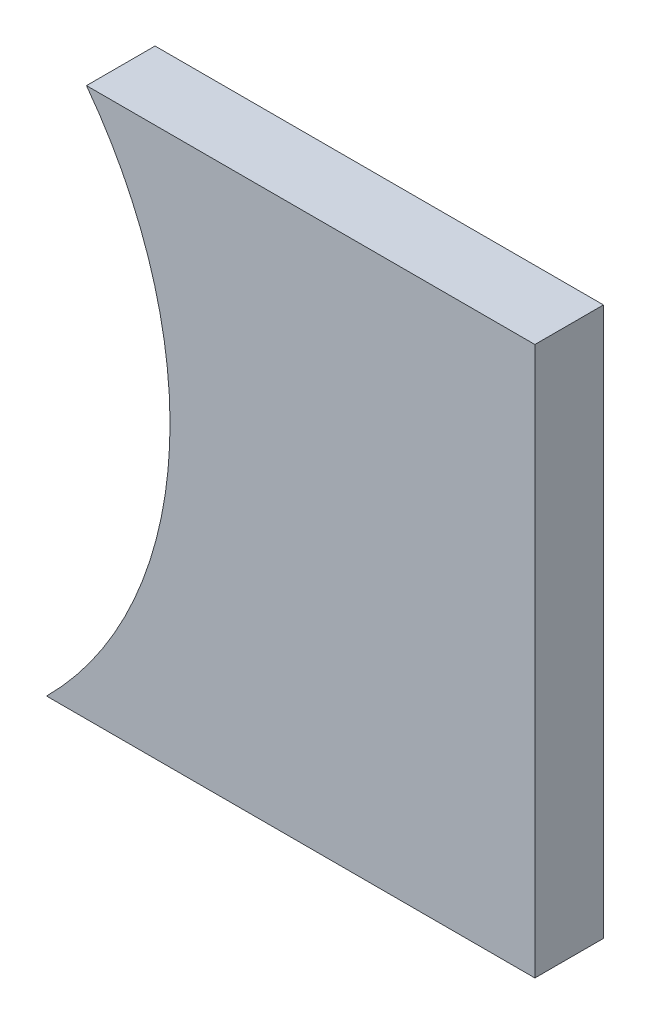
from build123d import *

# Parameters (mm, degrees)
DODANIE_WYCI_GNI_CIE1_DEPTH = 2
SZKIC2_W                    = 5
SZKIC2_H                    = 16
WYTNIJ_WYCI_GNI_CIE1_DEPTH  = 5
WYTNIJ_WYCI_GNI_CIE2_DEPTH  = 10


with BuildPart() as part:
    # Szkic1 → Dodanie-wyciągnięcie1 (new body)
    with BuildSketch(Plane.XY):
        Polygon((39.660703644, 7.348041155), (39.998203889, -8.651958845), (67.367690874, -8.651958845), (67.367690874, 7.348041155), align=None)
    extrude(amount=-DODANIE_WYCI_GNI_CIE1_DEPTH)

    # Szkic2 → Wytnij-wyciągnięcie1 (cut)
    with BuildSketch(Plane.XY):
        with Locations((64.867690874, -0.651958845)):
            Rectangle(SZKIC2_W, SZKIC2_H)
    extrude(amount=-WYTNIJ_WYCI_GNI_CIE1_DEPTH, mode=Mode.SUBTRACT)

    # Szkic3 → Wytnij-wyciągnięcie2 (cut)
    with BuildSketch(Plane.XY):
        with BuildLine():
            Line((39.660703644, 7.348041155), (39.998203889, -8.651958845))
            Line((39.998203889, -8.651958845), (48.125210145, -8.651958845))
            ThreePointArc((48.125210145, -8.651958845), (51.694710699, -0.869414217), (49.289973229, 7.348041155))
            Line((49.289973229, 7.348041155), (39.660703644, 7.348041155))
        make_face()
    extrude(amount=-WYTNIJ_WYCI_GNI_CIE2_DEPTH, mode=Mode.SUBTRACT)


solid = part.part
